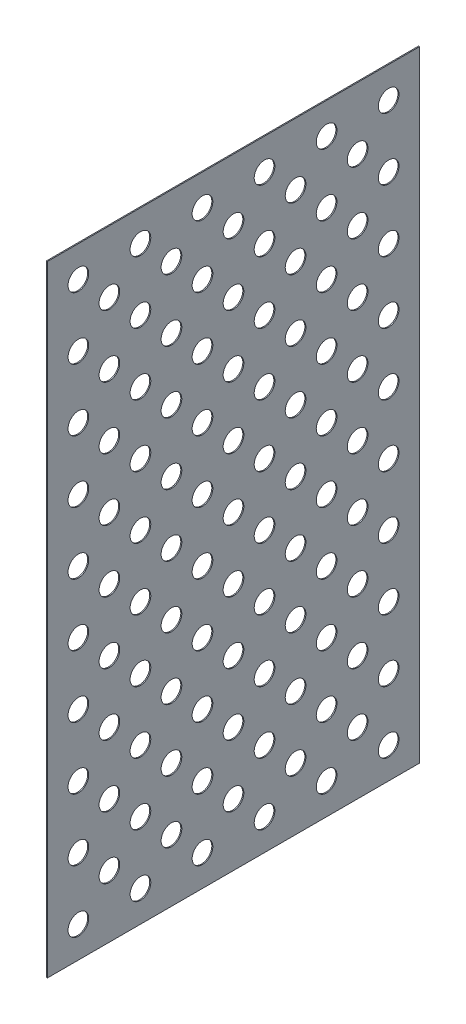
from build123d import *

# Parameters (mm, degrees)
SKETCH1_W           = 914.4
SKETCH1_H           = 1524
BOSS_EXTRUDE1_DEPTH = 2.54
SKETCH3_R           = 25.4
CUT_EXTRUDE1_DEPTH  = 3.54


with BuildPart() as part:
    # Sketch1 → Boss-Extrude1 (new body)
    with BuildSketch(Plane(origin=(0, 0, 0), x_dir=(0, 0, -1), z_dir=(1, 0, 0))):
        Rectangle(SKETCH1_W, SKETCH1_H)
    extrude(amount=BOSS_EXTRUDE1_DEPTH)

    # Sketch3 → Cut-Extrude1 (cut, through all)
    with BuildSketch(Plane.ZY):
        with Locations((-381, -685.8)):
            Circle(SKETCH3_R)
        with Locations((-304.8, -609.6)):
            Circle(SKETCH3_R)
        with Locations((-228.6, -685.8)):
            Circle(SKETCH3_R)
        with Locations((-76.2, -685.8)):
            Circle(SKETCH3_R)
        with Locations((76.2, -685.8)):
            Circle(SKETCH3_R)
        with Locations((228.6, -685.8)):
            Circle(SKETCH3_R)
        with Locations((381, -685.8)):
            Circle(SKETCH3_R)
        with Locations((-228.6, -533.4)):
            Circle(SKETCH3_R)
        with Locations((-76.2, -533.4)):
            Circle(SKETCH3_R)
        with Locations((76.2, -533.4)):
            Circle(SKETCH3_R)
        with Locations((228.6, -533.4)):
            Circle(SKETCH3_R)
        with Locations((381, -533.4)):
            Circle(SKETCH3_R)
        with Locations((-228.6, -381)):
            Circle(SKETCH3_R)
        with Locations((-76.2, -381)):
            Circle(SKETCH3_R)
        with Locations((76.2, -381)):
            Circle(SKETCH3_R)
        with Locations((228.6, -381)):
            Circle(SKETCH3_R)
        with Locations((381, -381)):
            Circle(SKETCH3_R)
        with Locations((-228.6, -228.6)):
            Circle(SKETCH3_R)
        with Locations((-76.2, -228.6)):
            Circle(SKETCH3_R)
        with Locations((76.2, -228.6)):
            Circle(SKETCH3_R)
        with Locations((228.6, -228.6)):
            Circle(SKETCH3_R)
        with Locations((381, -228.6)):
            Circle(SKETCH3_R)
        with Locations((-228.6, -76.2)):
            Circle(SKETCH3_R)
        with Locations((-76.2, -76.2)):
            Circle(SKETCH3_R)
        with Locations((76.2, -76.2)):
            Circle(SKETCH3_R)
        with Locations((228.6, -76.2)):
            Circle(SKETCH3_R)
        with Locations((381, -76.2)):
            Circle(SKETCH3_R)
        with Locations((-228.6, 76.2)):
            Circle(SKETCH3_R)
        with Locations((-76.2, 76.2)):
            Circle(SKETCH3_R)
        with Locations((76.2, 76.2)):
            Circle(SKETCH3_R)
        with Locations((228.6, 76.2)):
            Circle(SKETCH3_R)
        with Locations((381, 76.2)):
            Circle(SKETCH3_R)
        with Locations((-228.6, 228.6)):
            Circle(SKETCH3_R)
        with Locations((-76.2, 228.6)):
            Circle(SKETCH3_R)
        with Locations((76.2, 228.6)):
            Circle(SKETCH3_R)
        with Locations((228.6, 228.6)):
            Circle(SKETCH3_R)
        with Locations((381, 228.6)):
            Circle(SKETCH3_R)
        with Locations((-228.6, 381)):
            Circle(SKETCH3_R)
        with Locations((-76.2, 381)):
            Circle(SKETCH3_R)
        with Locations((76.2, 381)):
            Circle(SKETCH3_R)
        with Locations((228.6, 381)):
            Circle(SKETCH3_R)
        with Locations((381, 381)):
            Circle(SKETCH3_R)
        with Locations((-228.6, 533.4)):
            Circle(SKETCH3_R)
        with Locations((-76.2, 533.4)):
            Circle(SKETCH3_R)
        with Locations((76.2, 533.4)):
            Circle(SKETCH3_R)
        with Locations((228.6, 533.4)):
            Circle(SKETCH3_R)
        with Locations((381, 533.4)):
            Circle(SKETCH3_R)
        with Locations((-228.6, 685.8)):
            Circle(SKETCH3_R)
        with Locations((-76.2, 685.8)):
            Circle(SKETCH3_R)
        with Locations((76.2, 685.8)):
            Circle(SKETCH3_R)
        with Locations((228.6, 685.8)):
            Circle(SKETCH3_R)
        with Locations((381, 685.8)):
            Circle(SKETCH3_R)
        with Locations((-381, -533.4)):
            Circle(SKETCH3_R)
        with Locations((-381, -381)):
            Circle(SKETCH3_R)
        with Locations((-381, -228.6)):
            Circle(SKETCH3_R)
        with Locations((-381, -76.2)):
            Circle(SKETCH3_R)
        with Locations((-381, 76.2)):
            Circle(SKETCH3_R)
        with Locations((-381, 228.6)):
            Circle(SKETCH3_R)
        with Locations((-381, 381)):
            Circle(SKETCH3_R)
        with Locations((-381, 533.4)):
            Circle(SKETCH3_R)
        with Locations((-381, 685.8)):
            Circle(SKETCH3_R)
        with Locations((-152.4, -609.6)):
            Circle(SKETCH3_R)
        with Locations((0, -609.6)):
            Circle(SKETCH3_R)
        with Locations((152.4, -609.6)):
            Circle(SKETCH3_R)
        with Locations((304.8, -609.6)):
            Circle(SKETCH3_R)
        with Locations((-152.4, -457.2)):
            Circle(SKETCH3_R)
        with Locations((0, -457.2)):
            Circle(SKETCH3_R)
        with Locations((152.4, -457.2)):
            Circle(SKETCH3_R)
        with Locations((304.8, -457.2)):
            Circle(SKETCH3_R)
        with Locations((-152.4, -304.8)):
            Circle(SKETCH3_R)
        with Locations((0, -304.8)):
            Circle(SKETCH3_R)
        with Locations((152.4, -304.8)):
            Circle(SKETCH3_R)
        with Locations((304.8, -304.8)):
            Circle(SKETCH3_R)
        with Locations((-152.4, -152.4)):
            Circle(SKETCH3_R)
        with Locations((0, -152.4)):
            Circle(SKETCH3_R)
        with Locations((152.4, -152.4)):
            Circle(SKETCH3_R)
        with Locations((304.8, -152.4)):
            Circle(SKETCH3_R)
        with Locations((-152.4, 0)):
            Circle(SKETCH3_R)
        Circle(SKETCH3_R)
        with Locations((152.4, 0)):
            Circle(SKETCH3_R)
        with Locations((304.8, 0)):
            Circle(SKETCH3_R)
        with Locations((-152.4, 152.4)):
            Circle(SKETCH3_R)
        with Locations((0, 152.4)):
            Circle(SKETCH3_R)
        with Locations((152.4, 152.4)):
            Circle(SKETCH3_R)
        with Locations((304.8, 152.4)):
            Circle(SKETCH3_R)
        with Locations((-152.4, 304.8)):
            Circle(SKETCH3_R)
        with Locations((0, 304.8)):
            Circle(SKETCH3_R)
        with Locations((152.4, 304.8)):
            Circle(SKETCH3_R)
        with Locations((304.8, 304.8)):
            Circle(SKETCH3_R)
        with Locations((-152.4, 457.2)):
            Circle(SKETCH3_R)
        with Locations((0, 457.2)):
            Circle(SKETCH3_R)
        with Locations((152.4, 457.2)):
            Circle(SKETCH3_R)
        with Locations((304.8, 457.2)):
            Circle(SKETCH3_R)
        with Locations((-152.4, 609.6)):
            Circle(SKETCH3_R)
        with Locations((0, 609.6)):
            Circle(SKETCH3_R)
        with Locations((152.4, 609.6)):
            Circle(SKETCH3_R)
        with Locations((304.8, 609.6)):
            Circle(SKETCH3_R)
        with Locations((-304.8, -457.2)):
            Circle(SKETCH3_R)
        with Locations((-304.8, -304.8)):
            Circle(SKETCH3_R)
        with Locations((-304.8, -152.4)):
            Circle(SKETCH3_R)
        with Locations((-304.8, 0)):
            Circle(SKETCH3_R)
        with Locations((-304.8, 152.4)):
            Circle(SKETCH3_R)
        with Locations((-304.8, 304.8)):
            Circle(SKETCH3_R)
        with Locations((-304.8, 457.2)):
            Circle(SKETCH3_R)
        with Locations((-304.8, 609.6)):
            Circle(SKETCH3_R)
    extrude(amount=-CUT_EXTRUDE1_DEPTH, mode=Mode.SUBTRACT)


solid = part.part
